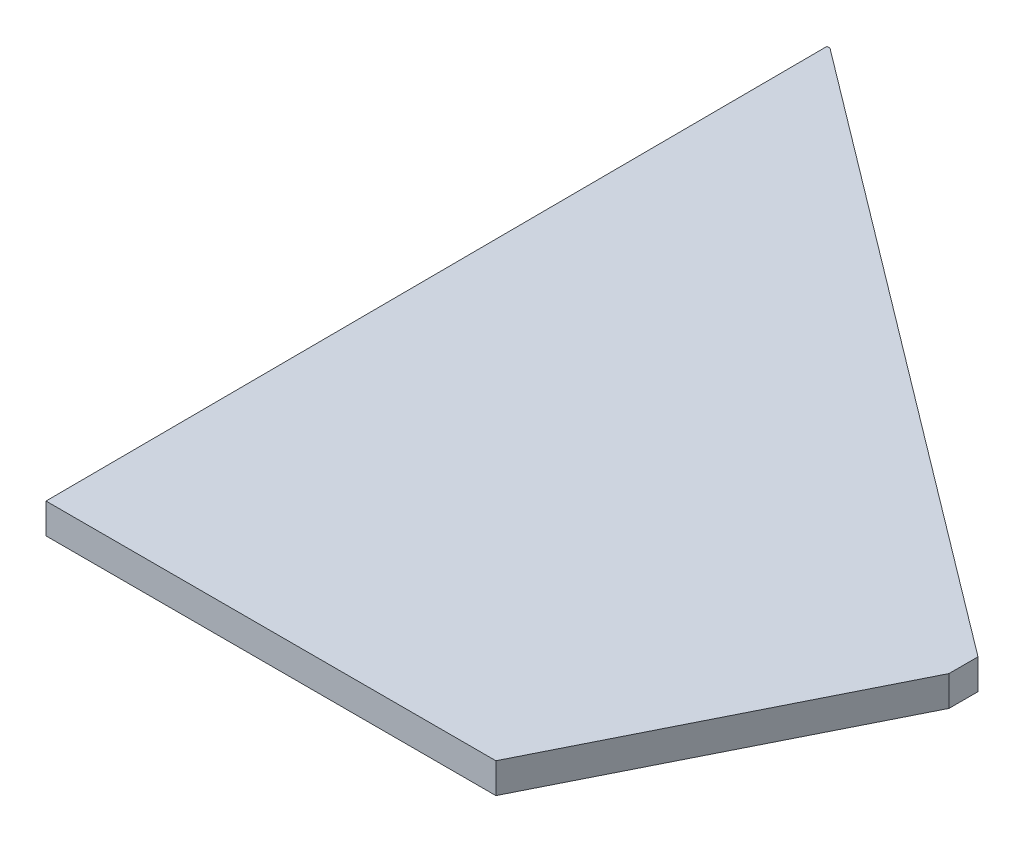
from build123d import *

# Parameters (mm, degrees)
BOSS_EXTRU_1_DEPTH = 2


with BuildPart() as part:
    # Esquisse1 → Boss.-Extru.1 (new body)
    with BuildSketch(Plane(origin=(0, 0, 0), x_dir=(1, 0, 0), z_dir=(0, 1, 0))):
        Polygon((39.783989371, 20), (39.783989371, 21.920125259), (-0.016010629, 51.920125259), (-0.216010629, 51.920125259), (0, 0), (29.783989371, 0), align=None)
    extrude(amount=BOSS_EXTRU_1_DEPTH)


solid = part.part
